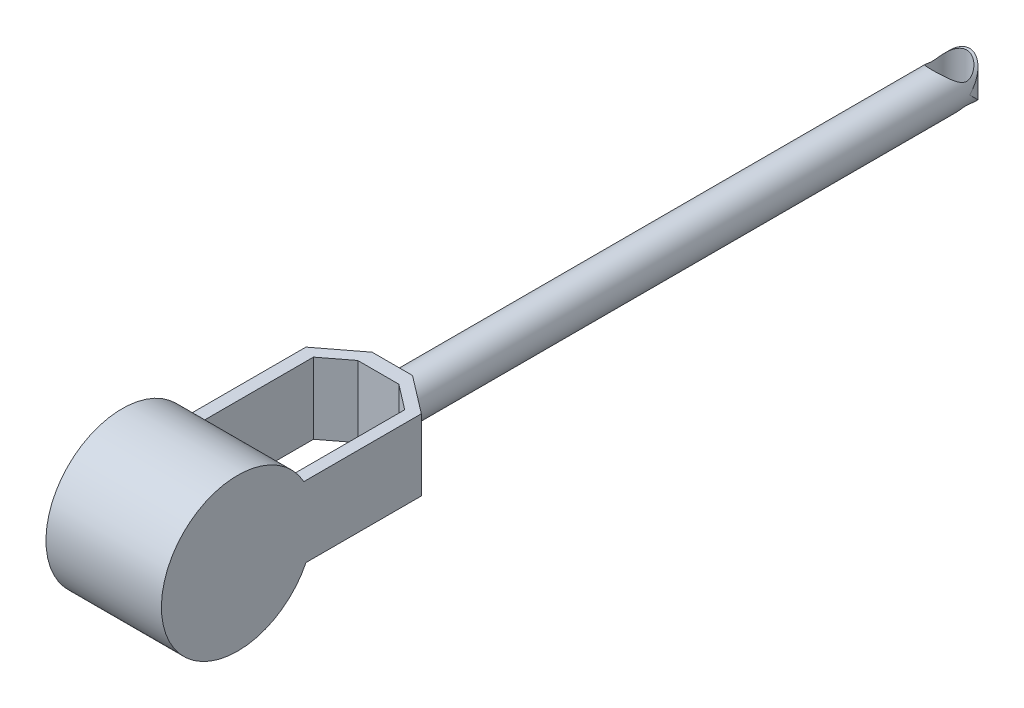
from build123d import *

# Parameters (mm, degrees)
SKETCH1_R           = 35.00000000000001
BOSS_EXTRUDE1_DEPTH = 1000
CUT_EXTRUDE1_DEPTH  = 750
SKETCH22_R          = 30
CUT_EXTRUDE2_DEPTH  = 750
SKETCH23_W          = 366.89615803266116
SKETCH23_H          = 201.36798200180615
BOSS_EXTRUDE2_DEPTH = 500
CUT_EXTRUDE4_DEPTH  = 500
SKETCH26_W          = 450.22684379892416
SKETCH26_H          = 39.01754234256356
CUT_EXTRUDE5_DEPTH  = 500
BOSS_EXTRUDE3_REACH = 1516.531
SKETCH27_R          = 131.99999999999994
CUT_EXTRUDE8_DEPTH  = 1520.3228139489233


with BuildPart() as part:
    # Sketch1 → Boss-Extrude1 (new body)
    with BuildSketch(Plane.XY):
        Circle(SKETCH1_R)
    extrude(amount=BOSS_EXTRUDE1_DEPTH)

    # Sketch21 → Cut-Extrude1 (cut, symmetric)
    with BuildSketch(Plane(origin=(0, 0, 0), x_dir=(1, 0, 0), z_dir=(0, 1, 0))):
        with BuildLine():
            ThreePointArc((0, 0), (-24.748737341529168, -10.251262658470836), (-35.00000000000001, -35.00000000000001))
            Line((-35.00000000000001, -35.00000000000001), (-35.00000000000001, 14.56189922191023))
            Line((-35.00000000000001, 14.56189922191023), (35.00000000000001, 14.56189922191023))
            Line((35.00000000000001, 14.56189922191023), (35.00000000000001, -35.000000000000085))
            ThreePointArc((35.00000000000001, -35.000000000000085), (24.748737341529196, -10.251262658470868), (0, 0))
        make_face()
    extrude(amount=CUT_EXTRUDE1_DEPTH, both=True, mode=Mode.SUBTRACT)

    # Sketch22 → Cut-Extrude2 (cut, symmetric)
    with BuildSketch(Plane(origin=(0, 0, 0), x_dir=(1, 0, 0), z_dir=(0, 1, 0))):
        with Locations(Location((0, -34.999999999999964, 0), (0, 0, 270))):
            Circle(SKETCH22_R)
    extrude(amount=CUT_EXTRUDE2_DEPTH, both=True, mode=Mode.SUBTRACT)

    # Sketch23 → Boss-Extrude2 (add)
    with BuildSketch(Plane.XY.offset(1000)):
        Rectangle(SKETCH23_W, SKETCH23_H)
    extrude(amount=BOSS_EXTRUDE2_DEPTH)

    # Sketch24 → Cut-Extrude4 (cut)
    with BuildSketch(Plane.XZ.offset(100.68399100090306)):
        Polygon((79.59360487116518, 1500), (-78.45567005550114, 1500), (-78.45567005550113, 1058.1623604619979), (-34.99999999999988, 1024.8865781005384), (36.137934815664146, 1024.8865781005381), (79.59360487116518, 1058.1623604619977), align=None)
        Polygon((-100, 1049.7731562010758), (-100, 1500), (-183.44807901633058, 1500), (-183.44807901633058, 1000), (-35, 1000), align=None)
        Polygon((100, 1049.7731562010758), (35.00000000000001, 1000), (183.44807901633058, 1000), (183.44807901633058, 1500), (100, 1500), align=None)
    extrude(amount=-CUT_EXTRUDE4_DEPTH, mode=Mode.SUBTRACT)

    # Sketch26 → Cut-Extrude5 (cut)
    with BuildSketch(Plane.ZY.offset(100)):
        with Locations((1274.886578100538, 81.1752198296213)):
            Rectangle(SKETCH26_W, SKETCH26_H)
        Polygon((1000, 61.66644865833952), (1049.7731562010758, 61.66644865833952), (1049.7731562010758, 100.68399100090308), (1024.8865781005381, 100.68399100090308), (1000, 100.68399100090308), align=None)
        Polygon((1500, -100.68399100090306), (1500, -61.666448658339505), (1049.7731562010758, -61.666448658339505), (1049.7731562010758, -100.68399100090305), align=None)
        Polygon((1049.7731562010758, -100.68399100090305), (1049.7731562010758, -61.66644865833949), (1000, -61.666448658339505), (1000, -100.68399100090306), align=None)
    extrude(amount=-CUT_EXTRUDE5_DEPTH, mode=Mode.SUBTRACT)

    # Boss-Extrude3: up to this face of the body (flat: up to its plane)
    boss_extrude3_end = Plane(part.part.faces().sort_by_distance((100, 0, 1274.886578101))[0])
    # Sketch27 → Boss-Extrude3 (add, up to the picked face)
    with BuildSketch(Plane.ZY.offset(100), mode=Mode.PRIVATE) as boss_extrude3_sk1:
        with Locations((1368, -3.431949648798167)):
            Circle(SKETCH27_R)
    boss_extrude3_tool1 = split(extrude(boss_extrude3_sk1.sketch, amount=-BOSS_EXTRUDE3_REACH, mode=Mode.PRIVATE), bisect_by=boss_extrude3_end, keep=Keep.BOTH, mode=Mode.PRIVATE)
    add(boss_extrude3_tool1.solids().sort_by(Axis((-100, -3.43195, 1368), (1, 0, 0)))[0])

    # Sketch28 → Cut-Extrude8 (cut, through all)
    with BuildSketch(Plane.ZY.offset(100)):
        with BuildLine():
            Line((1576.6741063083334, 113.68167915660561), (1386.7378452368366, 127.23133194125066))
            ThreePointArc((1386.7378452368366, 127.2313319412505), (1442.39663439627, 105.60538703230257), (1482.8311740680433, 61.66644865833952))
            Line((1482.8311740680433, 61.66644865833952), (1500, 61.66644865833952))
            Line((1500, 61.66644865833953), (1500, -3.4319477522261153))
            Line((1500, -3.4319477522261153), (1500, -61.666448658339505))
            Line((1500, -61.666448658339505), (1486.4598798121447, -61.666448658339505))
            ThreePointArc((1486.4598798121447, -61.666448658339476), (1437.7748025104354, -115.48317425000337), (1368, -135.43194964879822))
            Line((1368, -135.4319496487982), (1367.9999999999998, -201.07935807583712))
            Line((1367.9999999999998, -201.07935807583712), (1604.9218917009885, -125.07936404321737))
            Line((1604.9218917009885, -125.07936404321737), (1576.6741063083334, 113.68167915660561))
        make_face()
        with BuildLine():
            Line((1500, -61.666448658339505), (1500, -3.4319477522261153))
            ThreePointArc((1500, -3.431947752226116), (1496.5704169816079, -33.32589346983822), (1486.4598798121447, -61.666448658339476))
            Line((1486.4598798121447, -61.666448658339505), (1500, -61.666448658339505))
        make_face()
        with BuildLine():
            Line((1500, 61.66644865833952), (1482.8311740680433, 61.66644865833952))
            ThreePointArc((1482.8311740680433, 61.66644865833952), (1495.63564324576, 30.23023348362874), (1500, -3.431947752226116))
            Line((1500, -3.4319477522261153), (1500, 61.66644865833953))
        make_face()
    extrude(amount=-CUT_EXTRUDE8_DEPTH, mode=Mode.SUBTRACT)


solid = part.part
